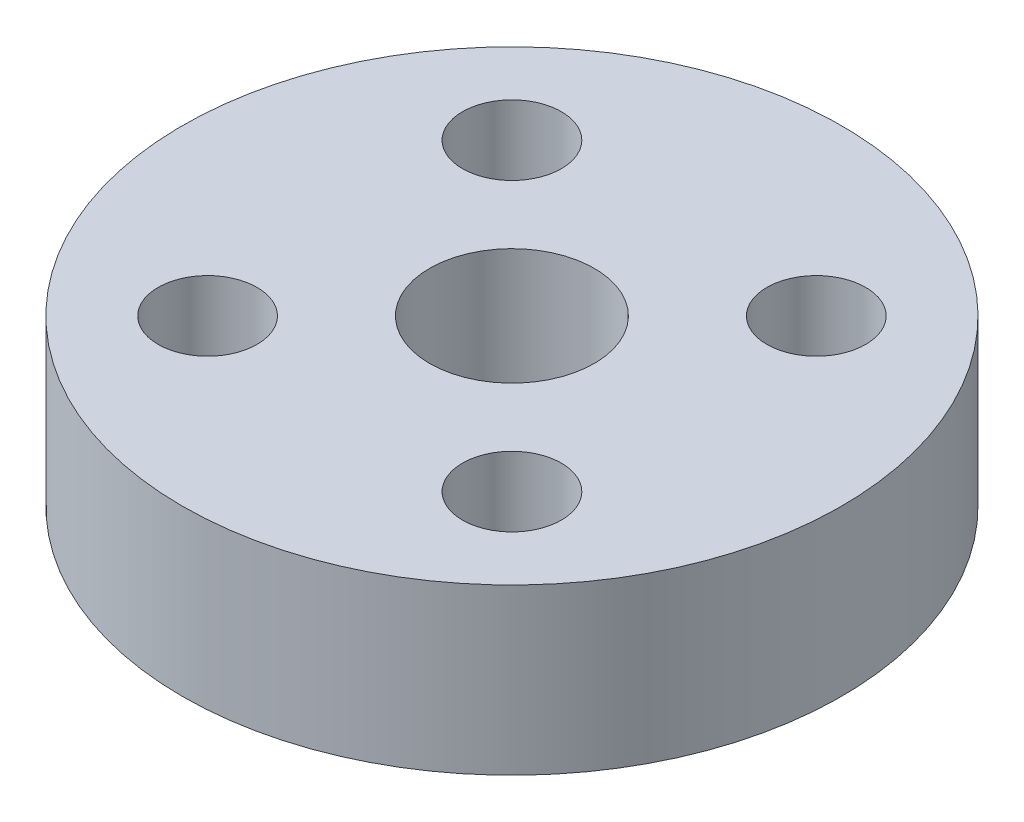
from build123d import *

# Parameters (mm, degrees)
SKETCH_1_R      = 1.5
EXTRUDE_1_DEPTH = 5


with BuildPart() as part:
    # Эскиз1 → Бобышка-Вытянуть1 (new body)
    with BuildSketch(Plane(origin=(0, 0, 0), x_dir=(1, 0, 0), z_dir=(0, 1, 0))):
        with BuildLine():
            Line((0, 10), (0, 2.5))
            ThreePointArc((0, 2.5), (0.956708581, 2.309698831), (1.767766953, 1.767766953))
            Line((1.767766953, 1.767766953), (3.556747109, 3.556747109))
            ThreePointArc((3.556747109, 3.556747109), (3.556747109, 5.678067453), (5.678067453, 5.678067453))
            Line((5.678067453, 5.678067453), (7.071067812, 7.071067812))
            ThreePointArc((7.071067812, 7.071067812), (3.826834324, 9.238795325), (0, 10))
        make_face()
        with BuildLine():
            ThreePointArc((2.5, 0), (-1.767766953, -1.767766953), (0, 2.5))
            Line((0, 2.5), (0, 10))
            ThreePointArc((0, 10), (-7.071067812, -7.071067812), (10, 0))
            ThreePointArc((10, 0), (9.238795325, 3.826834324), (7.071067812, 7.071067812))
            Line((7.071067812, 7.071067812), (5.678067453, 5.678067453))
            ThreePointArc((5.678067453, 5.678067453), (6.00322658, 5.19143243), (6.117407281, 4.617407281))
            ThreePointArc((6.117407281, 4.617407281), (5.19143243, 3.231587982), (3.556747109, 3.556747109))
            Line((3.556747109, 3.556747109), (1.767766953, 1.767766953))
            ThreePointArc((1.767766953, 1.767766953), (2.309698831, 0.956708581), (2.5, 0))
        make_face()
        with Locations((-4.617407281, -4.617407281)):
            Circle(SKETCH_1_R, mode=Mode.SUBTRACT)
        with Locations((4.617407281, -4.617407281)):
            Circle(SKETCH_1_R, mode=Mode.SUBTRACT)
        with Locations((-4.617407281, 4.617407281)):
            Circle(SKETCH_1_R, mode=Mode.SUBTRACT)
    extrude(amount=EXTRUDE_1_DEPTH)


solid = part.part
